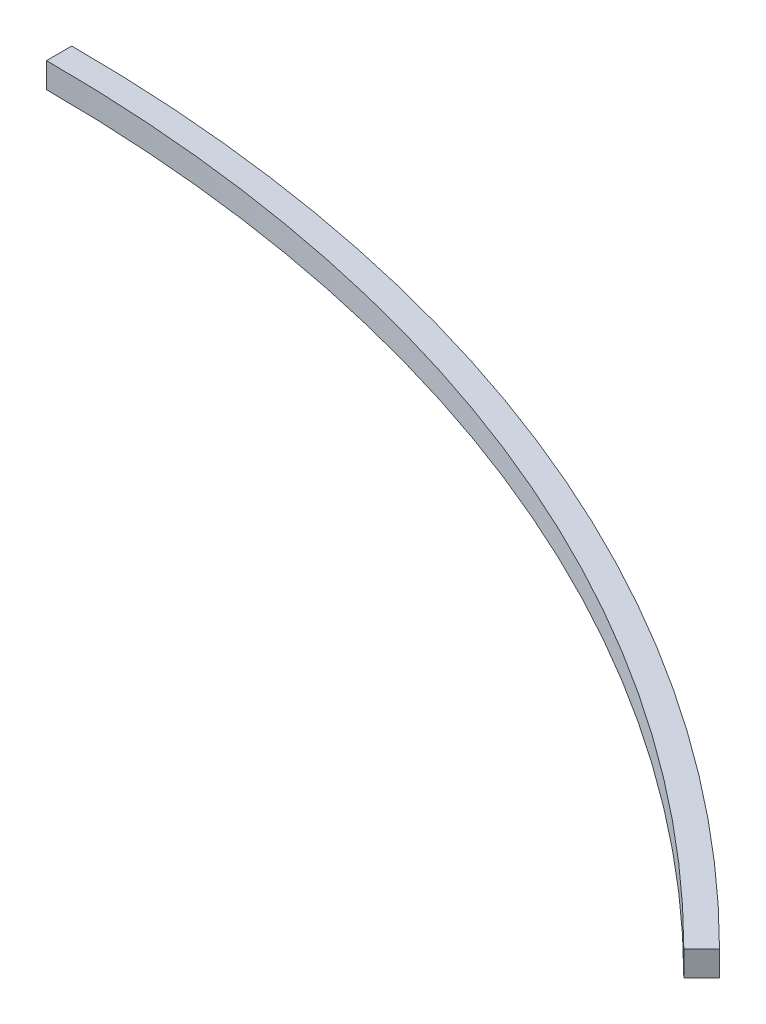
from build123d import *

# Parameters (mm, degrees)
BOSS_EXTRUDE1_DEPTH = 10


with BuildPart() as part:
    # Sketch1 → Boss-Extrude1 (new body)
    with BuildSketch(Plane(origin=(0, 0, 0), x_dir=(1, 0, 0), z_dir=(0, 1, 0))):
        with BuildLine():
            ThreePointArc((0, 620), (237.263728066, 572.805310157), (438.406204336, 438.406204336))
            Line((438.406204336, 438.406204336), (431.335136524, 431.335136524))
            ThreePointArc((431.335136524, 431.335136524), (233.436893743, 563.566514832), (0, 610))
            Line((0, 610), (0, 620))
        make_face()
    extrude(amount=BOSS_EXTRUDE1_DEPTH)


solid = part.part
